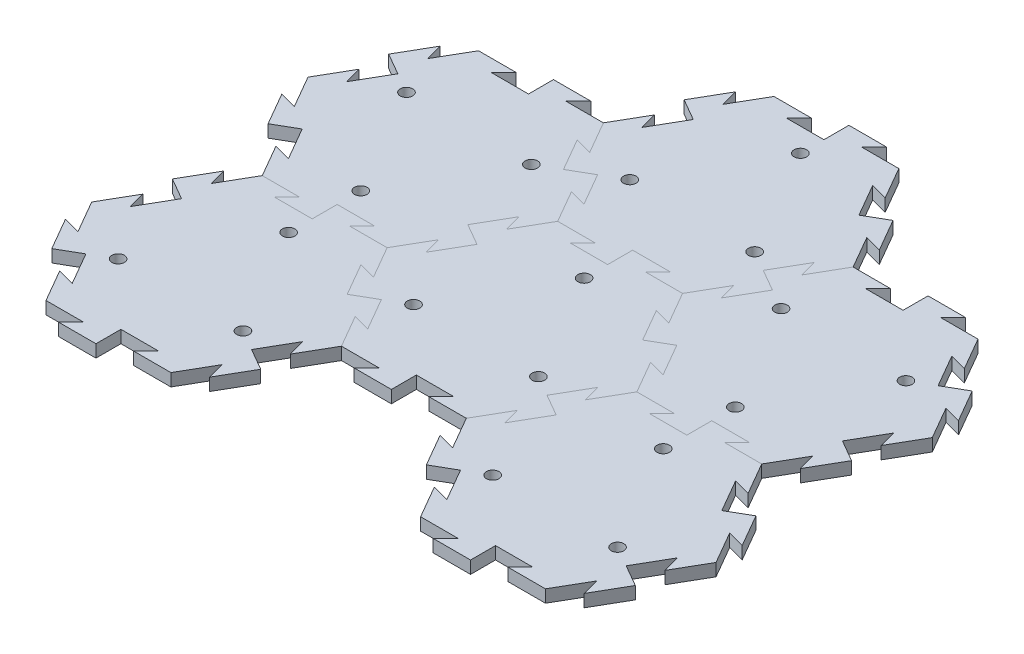
from build123d import *

# Parameters (mm, degrees)
BOSS_EXTRUDE1_DEPTH = 6.35
SKETCH9_R           = 3.175
CUT_EXTRUDE3_DEPTH  = 7.35
CIRPATTERN6_COUNT   = 3
CUT_EXTRUDE4_DEPTH  = 7.35
BOSS_EXTRUDE4_DEPTH = 6.35
CIRPATTERN7_COUNT   = 6
LPATTERN1_COUNT     = 2
LPATTERN1_PITCH     = 109.985226308
CIRPATTERN8_COUNT   = 5
CIRPATTERN8_ANGLE   = 240


with BuildPart() as part:
    # Sketch1 → Boss-Extrude1 (new body)
    with BuildSketch(Plane(origin=(0, 0, 0), x_dir=(1, 0, 0), z_dir=(0, 1, 0))):
        Polygon((63.5, 0), (31.75, 54.99261314), (-31.75, 54.99261314), (-63.5, 0), (-31.75, -54.99261314), (31.75, -54.99261314), align=None)
    extrude(amount=-BOSS_EXTRUDE1_DEPTH)

    # Sketch9 → Cut-Extrude3 (cut, through all)
    with BuildSketch(Plane(origin=(0, 0, 0), x_dir=(1, 0, 0), z_dir=(0, 1, 0))):
        with Locations((-31.75, -18.330871047)):
            Circle(SKETCH9_R)
    cut_extrude3 = extrude(amount=-CUT_EXTRUDE3_DEPTH, mode=Mode.SUBTRACT)

    # CirPattern6: Cut-Extrude3 ×3 about axis
    cirpattern6_axis = Axis((0, 0, 0), (0, 1, 0))
    for i in range(1, CIRPATTERN6_COUNT):
        add(cut_extrude3.rotate(cirpattern6_axis, i * 360 / CIRPATTERN6_COUNT), mode=Mode.SUBTRACT)

    # Sketch10 → Cut-Extrude4 (cut, through all)
    with BuildSketch(Plane(origin=(0, 0, 0), x_dir=(1, 0, 0), z_dir=(0, 1, 0))):
        Polygon((41.275, 38.494829198), (32.600738686, 40.819090512), (42.125738686, 24.32130657), (47.625, 27.49630657), align=None)
    cut_extrude4 = extrude(amount=-CUT_EXTRUDE4_DEPTH, mode=Mode.SUBTRACT)

    # Sketch11 → Boss-Extrude4 (add)
    with BuildSketch(Plane(origin=(0, 0, 0), x_dir=(1, 0, 0), z_dir=(0, 1, 0))):
        Polygon((47.625, 27.49630657), (53.124261314, 30.67130657), (62.649261314, 14.173522628), (53.975, 16.497783942), align=None)
    boss_extrude4 = extrude(amount=-BOSS_EXTRUDE4_DEPTH)

    # CirPattern7: Cut-Extrude4, Boss-Extrude4 ×6 about axis
    cirpattern7_axis = Axis((0, 0, 0), (0, 1, 0))
    for i in range(1, CIRPATTERN7_COUNT):
        add(cut_extrude4.rotate(cirpattern7_axis, i * 360 / CIRPATTERN7_COUNT), mode=Mode.SUBTRACT)
        add(boss_extrude4.rotate(cirpattern7_axis, i * 360 / CIRPATTERN7_COUNT))


with BuildPart() as lpattern1_1:
    # LPattern1: pattern copy
    add(part.part.moved(Location(Vector(0.866025404, 0, 0.5) * (1 * LPATTERN1_PITCH))))


with BuildPart() as cirpattern8_1:
    # CirPattern8: pattern copy
    add(lpattern1_1.part.rotate(Axis((0, 0, 0), (0, 1, 0)), 1 * CIRPATTERN8_ANGLE / (CIRPATTERN8_COUNT - 1)))


with BuildPart() as cirpattern8_2:
    # CirPattern8: pattern copy
    add(lpattern1_1.part.rotate(Axis((0, 0, 0), (0, 1, 0)), 2 * CIRPATTERN8_ANGLE / (CIRPATTERN8_COUNT - 1)))


with BuildPart() as cirpattern8_3:
    # CirPattern8: pattern copy
    add(lpattern1_1.part.rotate(Axis((0, 0, 0), (0, 1, 0)), 3 * CIRPATTERN8_ANGLE / (CIRPATTERN8_COUNT - 1)))


with BuildPart() as cirpattern8_4:
    # CirPattern8: pattern copy
    add(lpattern1_1.part.rotate(Axis((0, 0, 0), (0, 1, 0)), 4 * CIRPATTERN8_ANGLE / (CIRPATTERN8_COUNT - 1)))


solid = Compound([part.part, lpattern1_1.part, cirpattern8_1.part, cirpattern8_2.part, cirpattern8_3.part, cirpattern8_4.part])
